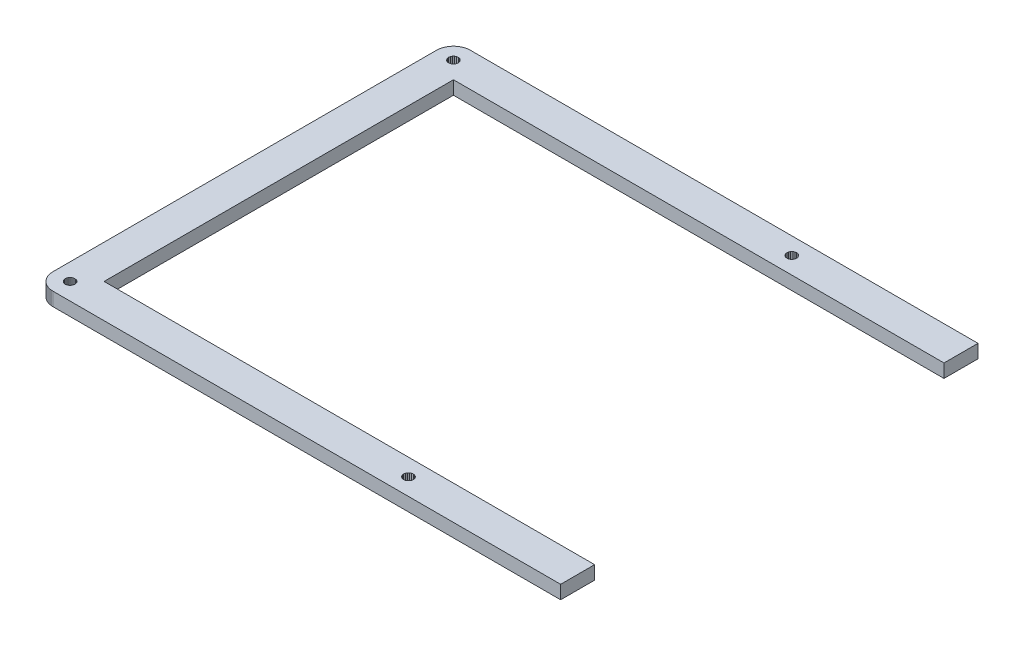
from build123d import *

# Parameters (mm, degrees)
BOSS_EXTRUDE2_DEPTH = 4.7625


with BuildPart() as part:
    # Sketch1 → Boss-Extrude2 (new body)
    with BuildSketch(Plane(origin=(0, 0, 0), x_dir=(1, 0, 0), z_dir=(0, 1, 0))):
        Polygon((185.950525, 135.919), (185.950525, 147.9675), (6.09505, 147.968), (5.62377, 147.949), (5.15525, 147.894), (4.6936, 147.803), (4.24021, 147.675), (3.79786, 147.511), (3.37068, 147.314), (2.96003, 147.085), (2.56728, 146.822), (2.19797, 146.529), (1.85208, 146.21), (1.53238, 145.865), (1.24024, 145.495), (0.978408, 145.102), (0.748273, 144.691), (0.551215, 144.264), (0.38723, 143.822), (0.259071, 143.368), (0.168121, 142.907), (0.112999, 142.44), (0.0950846, 141.967), (0.0937066, 6.0923), (0.112999, 5.62102), (0.168121, 5.15387), (0.259071, 4.69085), (0.38723, 4.23746), (0.551215, 3.79511), (0.748273, 3.36793), (0.978408, 2.95727), (1.24024, 2.56453), (1.53238, 2.19659), (1.85208, 1.84933), (2.19797, 1.52962), (2.56728, 1.23748), (2.96003, 0.975653), (3.37068, 0.745518), (3.79786, 0.549836), (4.24021, 0.385851), (4.6936, 0.257693), (5.15525, 0.165365), (5.62377, 0.110243), (6.09505, 0.0909507), (185.950525, 0.0909507), (185.950525, 12.1405), (12.1447, 12.1405), (12.1447, 135.919), align=None)
        Polygon((5.10565, 7.5117), (5.58518, 7.75698), (6.11851, 7.84105), (6.65318, 7.75698), (7.13274, 7.5117), (7.51445, 7.12996), (7.75974, 6.65043), (7.8438, 6.11572), (7.75974, 5.5838), (7.51445, 5.10286), (7.13274, 4.72115), (6.65318, 4.47587), (6.11851, 4.3918), (5.58518, 4.47587), (5.10565, 4.72115), (4.72391, 5.10286), (4.47862, 5.5838), (4.39318, 6.11572), (4.47862, 6.65043), (4.72391, 7.12996), align=None, mode=Mode.SUBTRACT)
        Polygon((124.992, 7.5117), (125.473, 7.75698), (126.007, 7.84105), (126.54, 7.75698), (127.021, 7.5117), (127.403, 7.12996), (127.648, 6.65043), (127.732, 6.11572), (127.648, 5.5838), (127.403, 5.10286), (127.021, 4.72115), (126.54, 4.47587), (126.007, 4.3918), (125.473, 4.47587), (124.992, 4.72115), (124.612, 5.10286), (124.365, 5.5838), (124.281, 6.11572), (124.365, 6.65043), (124.612, 7.12996), align=None, mode=Mode.SUBTRACT)
        Polygon((5.10565, 143.338), (5.58518, 143.583), (6.11851, 143.667), (6.65318, 143.583), (7.13274, 143.338), (7.51445, 142.956), (7.75974, 142.477), (7.8438, 141.942), (7.75974, 141.409), (7.51445, 140.929), (7.13274, 140.547), (6.65318, 140.302), (6.11851, 140.217), (5.58518, 140.302), (5.10565, 140.547), (4.72391, 140.929), (4.47862, 141.409), (4.39318, 141.942), (4.47862, 142.477), (4.72391, 142.956), align=None, mode=Mode.SUBTRACT)
        Polygon((124.992, 143.338), (125.473, 143.583), (126.007, 143.667), (126.54, 143.583), (127.021, 143.338), (127.403, 142.956), (127.648, 142.477), (127.732, 141.942), (127.648, 141.409), (127.403, 140.929), (127.021, 140.547), (126.54, 140.302), (126.007, 140.217), (125.473, 140.302), (124.992, 140.547), (124.612, 140.929), (124.365, 141.409), (124.281, 141.942), (124.365, 142.477), (124.612, 142.956), align=None, mode=Mode.SUBTRACT)
    extrude(amount=BOSS_EXTRUDE2_DEPTH)


solid = part.part
